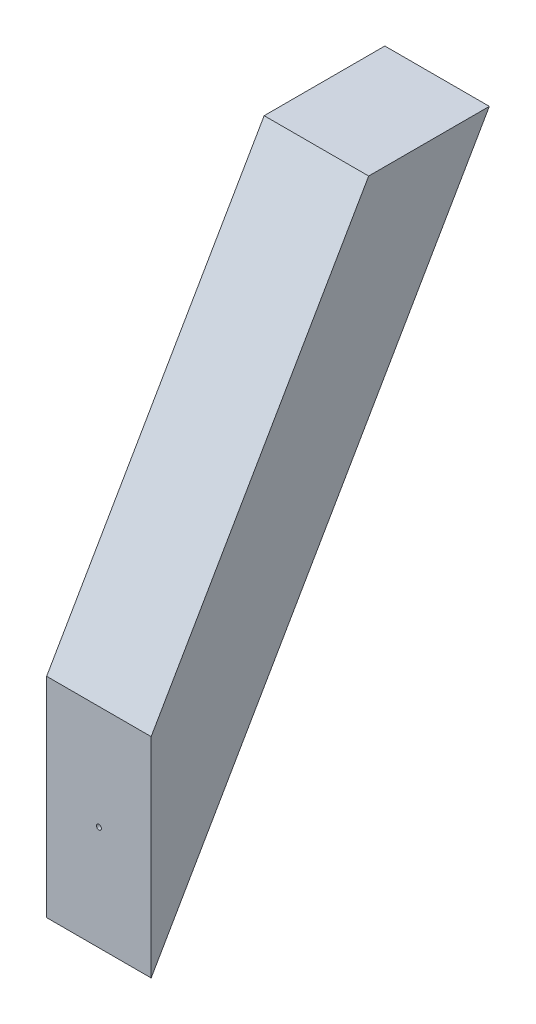
from build123d import *

# Parameters (mm, degrees)
BOSS_EXTRUDE1_DEPTH       = 12.7
F_0_80_TAPPED_HOLE1_D     = 1.19126
F_0_80_TAPPED_HOLE1_DEPTH = 10
F_0_80_TAPPED_HOLE1_TIP   = 0.357890611


with BuildPart() as part:
    # Sketch1 → Boss-Extrude1 (new body, symmetric)
    with BuildSketch(Plane(origin=(0, 0, 0), x_dir=(0, 0, -1), z_dir=(1, 0, 0))):
        Polygon((0, 0), (0, 50.8), (52.861, 142.357937739), (82.190393675, 142.357937739), align=None)
    extrude(amount=BOSS_EXTRUDE1_DEPTH, both=True)

    # #0-80 Tapped Hole1
    with Locations(Plane.XY):
        with Locations((0, 25.4)):
            Hole(F_0_80_TAPPED_HOLE1_D / 2, depth=F_0_80_TAPPED_HOLE1_DEPTH)
            with Locations((0, 0, -(F_0_80_TAPPED_HOLE1_DEPTH + F_0_80_TAPPED_HOLE1_TIP / 2))):  # 118° drill point
                Cone(0, F_0_80_TAPPED_HOLE1_D / 2, F_0_80_TAPPED_HOLE1_TIP, mode=Mode.SUBTRACT)


solid = part.part
